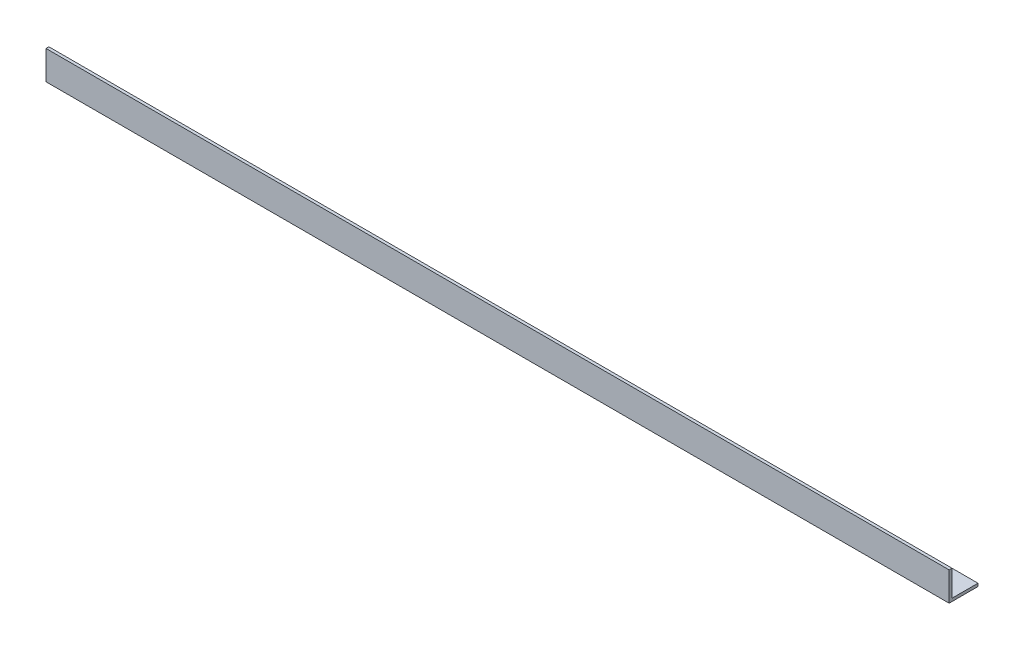
from build123d import *

# Parameters (mm, degrees)
EXTRUDE_1_DEPTH = 469


with BuildPart() as part:
    # Эскиз1 → Бобышка-Вытянуть1 (new body)
    with BuildSketch(Plane(origin=(0, 0, 0), x_dir=(0, 0, -1), z_dir=(1, 0, 0))):
        Polygon((0, 0), (0, 15), (1.5, 15), (1.5, 1.5), (15, 1.5), (15, 0), align=None)
    extrude(amount=EXTRUDE_1_DEPTH)


solid = part.part
